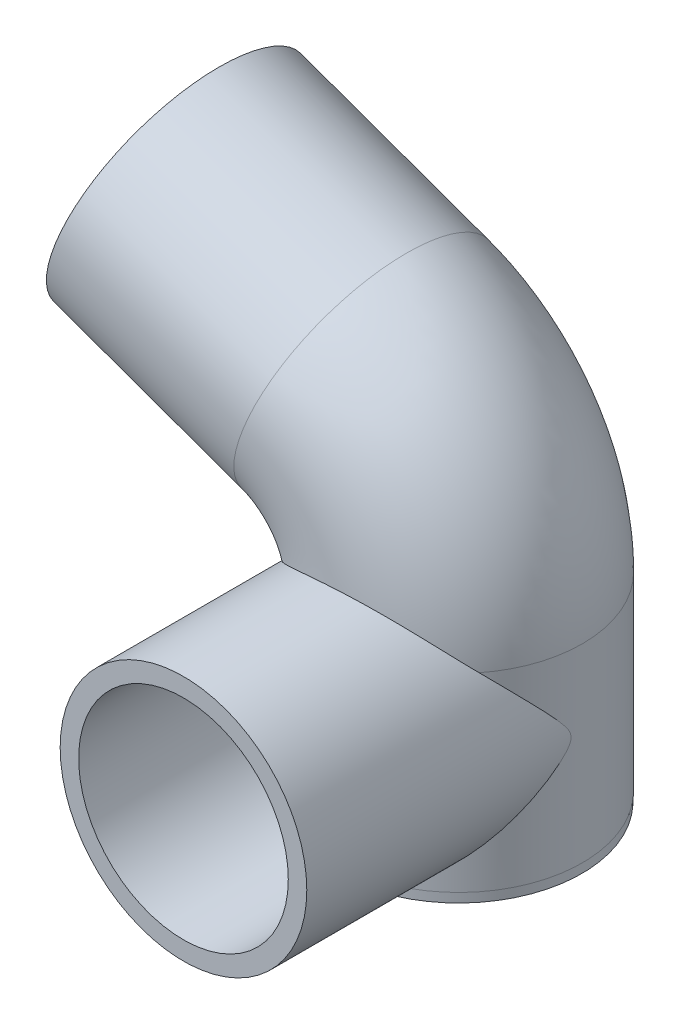
from build123d import *

# Parameters (mm, degrees)
CROQUIS1_R                          = 13
CROQUIS1_R_2                        = 11.05
SALIENTE_EXTRUIR1_DEPTH             = 1
BARRER_L_MINA1_PROFILE_R            = 13.05
BARRER_L_MINA1_PROFILE_R_2          = 11.05
CROQUIS19_R                         = 13
CROQUIS19_R_2                       = 11.05
SALIENTE_EXTRUIR2_DEPTH             = 14
SALIENTE_EXTRUIR2_DIRECTION_2_REACH = 72.145
CORTAR_EXTRUIR1_REACH               = 78.822
CROQUIS20_R                         = 11.05


with BuildPart() as part:
    # Croquis1 → Saliente-Extruir1 (new body)
    with BuildSketch(Plane(origin=(0, 0, 0), x_dir=(1, 0, 0), z_dir=(0, 1, 0))):
        with Locations(Location((0, 0, 0), (0, 0, 270))):
            Circle(CROQUIS1_R)
        with Locations(Location((0, 0, 0), (0, 0, 270))):
            Circle(CROQUIS1_R_2, mode=Mode.SUBTRACT)
    extrude(amount=SALIENTE_EXTRUIR1_DEPTH)

    # Barrer-L_mina1: sweep along a path in Croquis2
    with BuildLine(Plane.XY) as barrer_l_mina1_path:
        Line((0, 1), (0, 21))
        ThreePointArc((0, 21), (-2.727754239, 29.625078781), (-9.918931196, 35.113211534))
        Line((-9.918931196, 35.113211534), (-29.677427344, 42.226707859))
    # Barrer-L_mina1 profile (on start of the path) → Barrer-L_mina1 (sweep)
    with BuildSketch(Plane.ZX.offset(1)):
        Circle(BARRER_L_MINA1_PROFILE_R)
        Circle(BARRER_L_MINA1_PROFILE_R_2, mode=Mode.SUBTRACT)
    sweep(path=barrer_l_mina1_path.line)

    # Croquis19 → Saliente-Extruir2 (add)
    with BuildSketch(Plane.XY.offset(15)):
        with Locations((0, 13)):
            Circle(CROQUIS19_R)
        with Locations((0, 13)):
            Circle(CROQUIS19_R_2, mode=Mode.SUBTRACT)
    extrude(amount=SALIENTE_EXTRUIR2_DEPTH)

    # Croquis19 → Saliente-Extruir2 direction 2 (add, up to next)
    with BuildSketch(Plane.XY.offset(15), mode=Mode.PRIVATE) as saliente_extruir2_direction_2_sk1:
        with Locations((0, 13)):
            Circle(CROQUIS19_R)
        with Locations((0, 13)):
            Circle(CROQUIS19_R_2, mode=Mode.SUBTRACT)
    saliente_extruir2_direction_2_tool1 = extrude(saliente_extruir2_direction_2_sk1.sketch, amount=-SALIENTE_EXTRUIR2_DIRECTION_2_REACH, mode=Mode.PRIVATE) - part.part
    add(saliente_extruir2_direction_2_tool1.solids().sort_by_distance((-12.632304, 13, 15))[0])

    # Croquis20 → Cortar-Extruir1 (cut, up to next)
    with BuildSketch(Plane.XY.offset(29), mode=Mode.PRIVATE) as cortar_extruir1_sk1:
        with Locations((0, 13)):
            Circle(CROQUIS20_R)
    cortar_extruir1_tool1 = extrude(cortar_extruir1_sk1.sketch, amount=-CORTAR_EXTRUIR1_REACH, mode=Mode.PRIVATE) & part.part
    add(cortar_extruir1_tool1.solids().sort_by_distance((0, 13, 29))[0], mode=Mode.SUBTRACT)


solid = part.part
